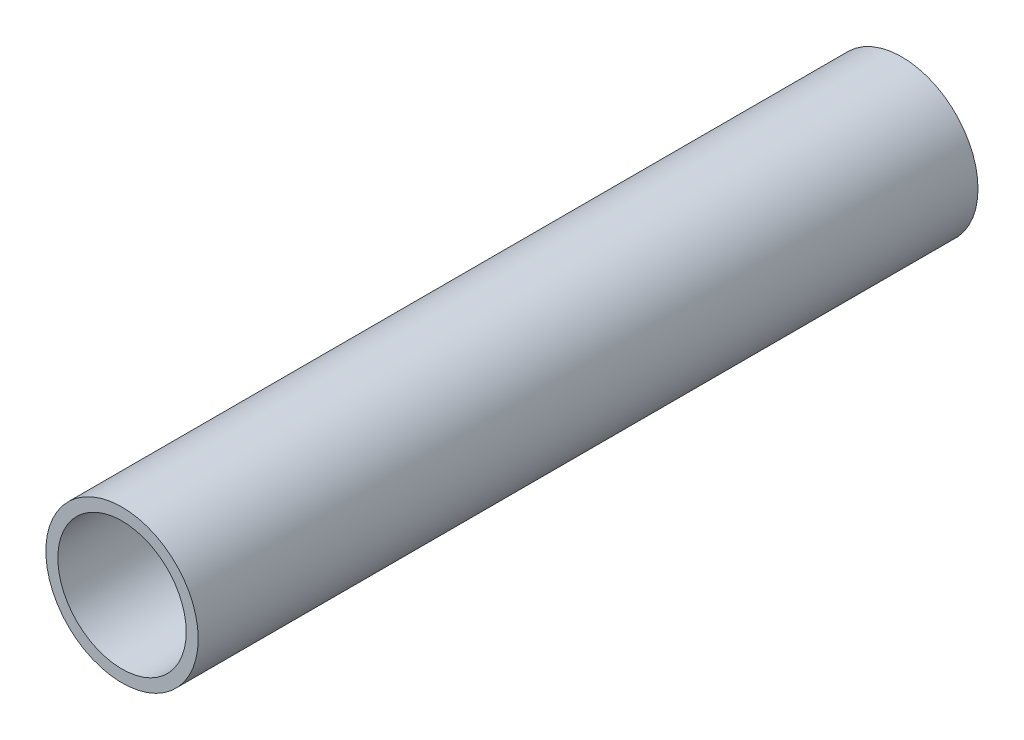
from build123d import *

# Parameters (mm, degrees)
SKETCH1_R           = 12.7
SKETCH1_R_2         = 10.7
BOSS_EXTRUDE1_DEPTH = 130


with BuildPart() as part:
    # Sketch1 → Boss-Extrude1 (new body)
    with BuildSketch(Plane.XY):
        Circle(SKETCH1_R)
        Circle(SKETCH1_R_2, mode=Mode.SUBTRACT)
    extrude(amount=BOSS_EXTRUDE1_DEPTH)


solid = part.part
